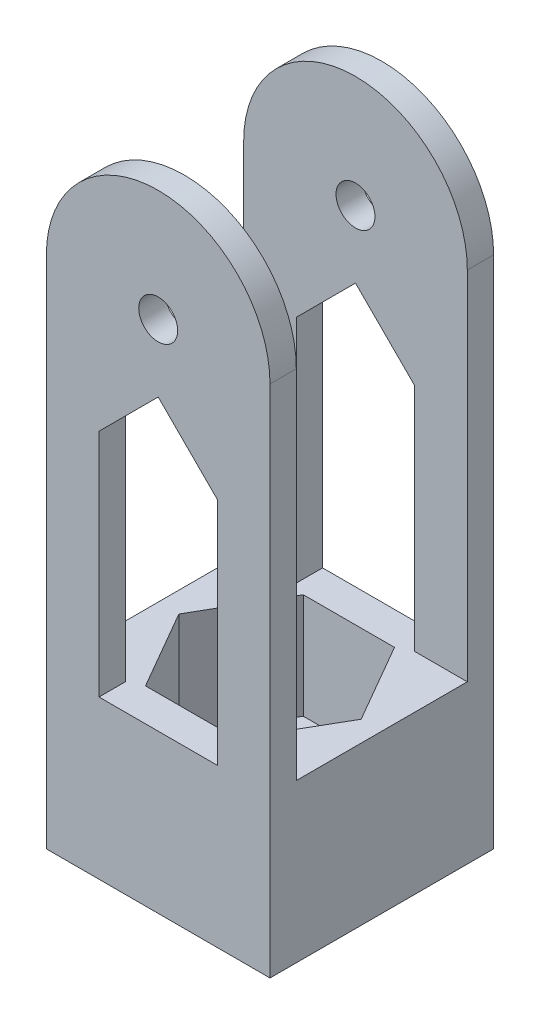
from build123d import *

# Parameters (mm, degrees)
SKETCH1_W           = 26.9875
SKETCH1_H           = 26.9875
BOSS_EXTRUDE1_DEPTH = 19.05
SKETCH2_R           = 6.985
CUT_EXTRUDE1_DEPTH  = 20.05
CUT_EXTRUDE4_DEPTH  = 12.7
SKETCH4_R           = 2.3495
BOSS_EXTRUDE2_DEPTH = 3.175
CUT_EXTRUDE5_DEPTH  = 27.9875


with BuildPart() as part:
    # Sketch1 → Boss-Extrude1 (new body)
    with BuildSketch(Plane(origin=(0, 0, 0), x_dir=(1, 0, 0), z_dir=(0, 1, 0))):
        with Locations((13.49375, 13.49375)):
            Rectangle(SKETCH1_W, SKETCH1_H)
    extrude(amount=BOSS_EXTRUDE1_DEPTH)

    # Sketch2 → Cut-Extrude1 (cut, through all)
    with BuildSketch(Plane(origin=(0, 19.05, 0), x_dir=(1, 0, 0), z_dir=(0, 1, 0))):
        with Locations((13.49375, 13.49375)):
            Circle(SKETCH2_R)
    extrude(amount=-CUT_EXTRUDE1_DEPTH, mode=Mode.SUBTRACT)

    # Sketch3 → Cut-Extrude4 (cut)
    with BuildSketch(Plane(origin=(0, 19.05, 0), x_dir=(1, 0, 0), z_dir=(0, 1, 0))):
        Polygon((18.993011314, 23.01875), (7.994488686, 23.01875), (2.495227372, 13.49375), (7.994488686, 3.96875), (18.993011314, 3.96875), (24.492272628, 13.49375), align=None)
    extrude(amount=-CUT_EXTRUDE4_DEPTH, mode=Mode.SUBTRACT)

    # Sketch4 → Boss-Extrude2 (add)
    with BuildSketch(Plane(origin=(0, 0, -26.9875), x_dir=(-1, 0, 0), z_dir=(0, 0, -1))):
        with BuildLine():
            Line((0, 19.05), (-26.9875, 19.05))
            Line((-26.9875, 19.05), (-26.9875, 62.0875))
            ThreePointArc((-26.9875, 62.0875), (-13.49375, 75.58125), (0, 62.0875))
            Line((0, 62.0875), (0, 19.05))
        make_face()
        with Locations((-13.49375, 62.0875)):
            Circle(SKETCH4_R, mode=Mode.SUBTRACT)
    boss_extrude2 = extrude(amount=-BOSS_EXTRUDE2_DEPTH)

    # Mirror1: Boss-Extrude2 across plane
    add(boss_extrude2.mirror(Plane(origin=(0, 0, -13.49375), x_dir=(1, 0, 0), z_dir=(0, 0, -1))))

    # Sketch6 → Cut-Extrude5 (cut, through all)
    with BuildSketch(Plane(origin=(0, 0, -26.9875), x_dir=(-1, 0, 0), z_dir=(0, 0, -1))):
        Polygon((-20.6375, 46.83125), (-13.49375, 53.975), (-6.35, 46.83125), (-6.35, 19.05), (-20.6375, 19.05), align=None)
    extrude(amount=-CUT_EXTRUDE5_DEPTH, mode=Mode.SUBTRACT)


solid = part.part
